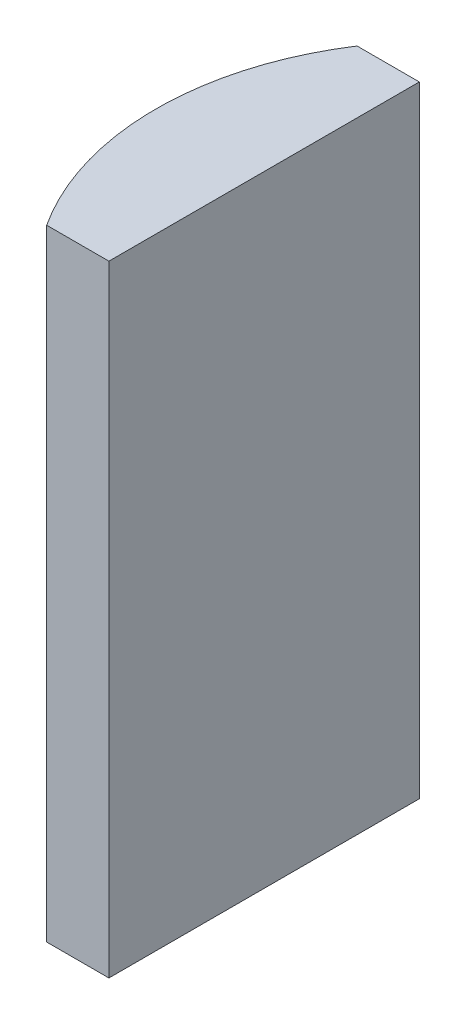
from build123d import *

# Parameters (mm, degrees)
EXTRUDE_1_DEPTH = 20


with BuildPart() as part:
    # 草图1 → 凸台-拉伸1 (new body)
    with BuildSketch(Plane(origin=(0, 0, 0), x_dir=(1, 0, 0), z_dir=(0, 1, 0))):
        with BuildLine():
            Line((-3.319794036, 5), (-1.314795665, 5))
            Line((-1.314795665, 5), (-1.314795665, -5))
            Line((-1.314795665, -5), (-3.319794036, -5))
            ThreePointArc((-3.319794036, -5), (-4.804795665, 0), (-3.319794036, 5))
        make_face()
    extrude(amount=EXTRUDE_1_DEPTH)


solid = part.part
